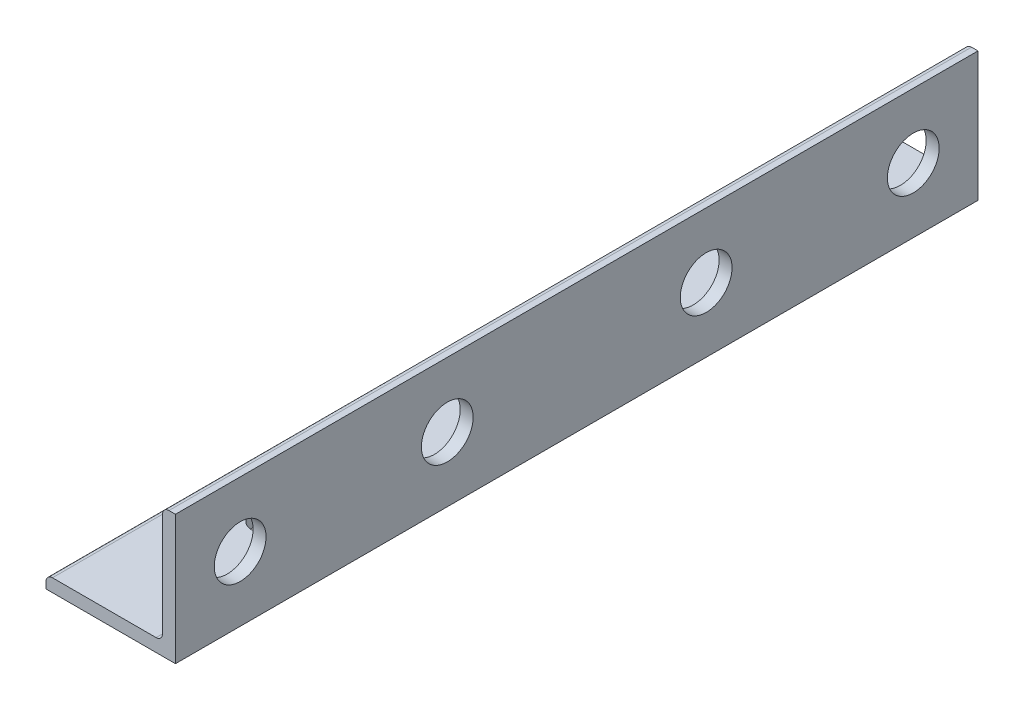
from build123d import *

# Parameters (mm, degrees)
BOSS_EXTRUDE1_DEPTH = 49.2125
SKETCH3_R           = 3.175
CUT_EXTRUDE1_DEPTH  = 16.875
SKETCH4_R           = 1.7500092
CUT_EXTRUDE2_DEPTH  = 16.875


with BuildPart() as part:
    # Sketch2 → Boss-Extrude1 (new body, symmetric)
    with BuildSketch(Plane.XY):
        with BuildLine():
            Line((-7.9375, 0), (7.9375, 0))
            Line((7.9375, 0), (7.9375, 15.875))
            Line((7.9375, 15.875), (7.14375, 15.875))
            ThreePointArc((7.14375, 15.875), (6.582483992, 15.642516008), (6.35, 15.08125))
            Line((6.35, 15.08125), (6.35, 2.38125))
            ThreePointArc((6.35, 2.38125), (6.117516008, 1.819983992), (5.55625, 1.5875))
            Line((5.55625, 1.5875), (-7.14375, 1.5875))
            ThreePointArc((-7.14375, 1.5875), (-7.705016008, 1.355016008), (-7.9375, 0.79375))
            Line((-7.9375, 0.79375), (-7.9375, 0))
        make_face()
    extrude(amount=BOSS_EXTRUDE1_DEPTH, both=True)

    # Sketch3 → Cut-Extrude1 (cut, through all)
    with BuildSketch(Plane(origin=(7.9375, 0, 0), x_dir=(0, 0, -1), z_dir=(1, 0, 0))):
        with Locations((-41.275, 7.9375)):
            Circle(SKETCH3_R)
        with Locations((41.275, 7.9375)):
            Circle(SKETCH3_R)
        with Locations((-15.875, 7.9375)):
            Circle(SKETCH3_R)
        with Locations((15.875, 7.9375)):
            Circle(SKETCH3_R)
    extrude(amount=-CUT_EXTRUDE1_DEPTH, mode=Mode.SUBTRACT)

    # Sketch4 → Cut-Extrude2 (cut, through all)
    with BuildSketch(Plane.XZ):
        with Locations((0, -30.1625)):
            Circle(SKETCH4_R)
        with Locations((0, 30.1625)):
            Circle(SKETCH4_R)
    extrude(amount=-CUT_EXTRUDE2_DEPTH, mode=Mode.SUBTRACT)


solid = part.part
